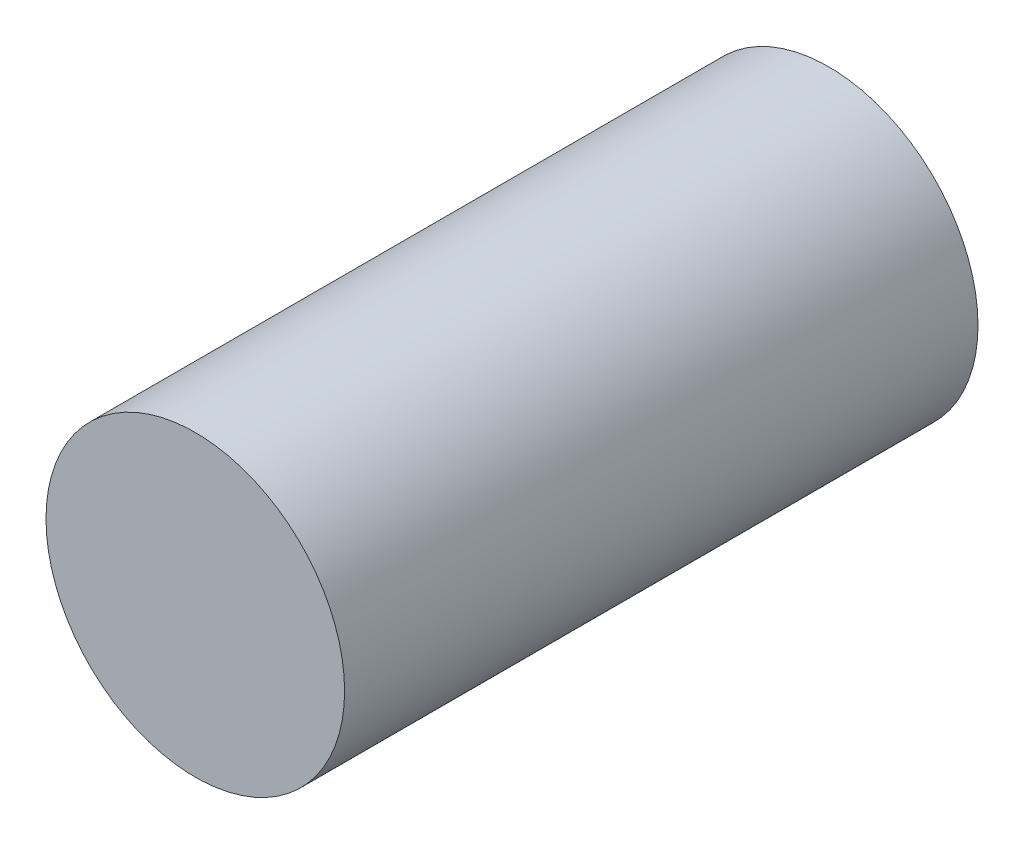
from build123d import *

# Parameters (mm, degrees)
SKETCH1_R           = 16.5
BOSS_EXTRUDE1_DEPTH = 70


with BuildPart() as part:
    # Sketch1 → Boss-Extrude1 (new body)
    with BuildSketch(Plane.XY):
        Circle(SKETCH1_R)
    extrude(amount=BOSS_EXTRUDE1_DEPTH)


solid = part.part
